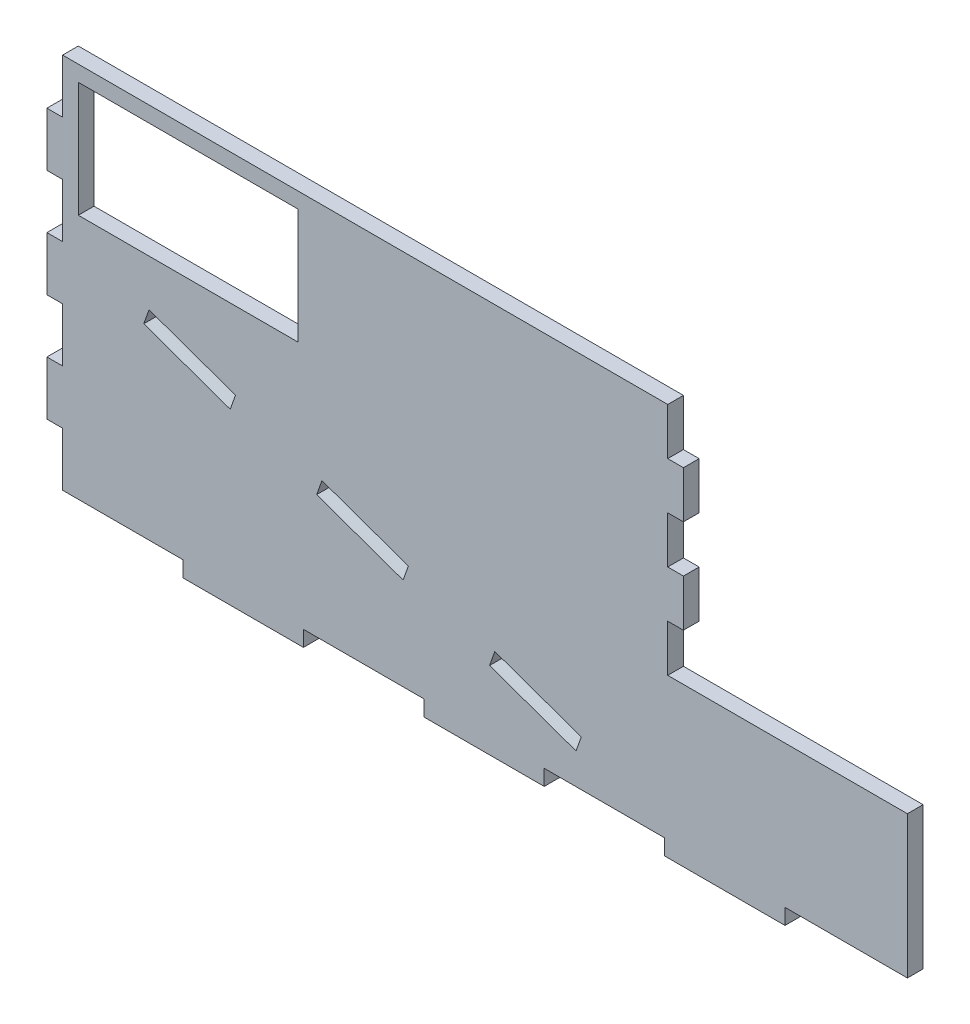
from build123d import *

# Parameters (mm, degrees)
SKETCH1_W           = 115.6
SKETCH1_H           = 72
BOSS_EXTRUDE1_DEPTH = 3
CUT_EXTRUDE1_REACH  = 5
SKETCH2_W           = 42
SKETCH2_H           = 22
SKETCH3_W           = 3
SKETCH3_H           = 10.29
SKETCH3_H_2         = 8.964
BOSS_EXTRUDE2_DEPTH = 3
SKETCH6_W           = 45.782864491
SKETCH6_H           = 27.18
BOSS_EXTRUDE4_DEPTH = 3
SKETCH8_W           = 23
SKETCH8_H           = 3
BOSS_EXTRUDE5_DEPTH = 3


with BuildPart() as part:
    # Sketch1 → Boss-Extrude1 (new body)
    with BuildSketch(Plane.XY):
        with Locations((57.8, 36)):
            Rectangle(SKETCH1_W, SKETCH1_H)
        Polygon((16.514285714, 38.123846184), (15.508587017, 35.297440316), (32.022872733, 29.421286499), (33.02857143, 32.247692367), align=None, mode=Mode.SUBTRACT)
        Polygon((49.542857146, 26.37153855), (48.537158448, 23.545132682), (65.051444164, 17.668978865), (66.057142861, 20.495384733), align=None, mode=Mode.SUBTRACT)
        Polygon((82.571428577, 14.619230916), (81.56572988, 11.792825048), (98.080015595, 5.916671232), (99.085714292, 8.743077099), align=None, mode=Mode.SUBTRACT)
    extrude(amount=BOSS_EXTRUDE1_DEPTH)

    # Sketch2 → Cut-Extrude1 (cut, up to next)
    with BuildSketch(Plane.XY.offset(3), mode=Mode.PRIVATE) as cut_extrude1_sk1:
        with Locations((24, 58)):
            Rectangle(SKETCH2_W, SKETCH2_H)
    cut_extrude1_tool1 = extrude(cut_extrude1_sk1.sketch, amount=-CUT_EXTRUDE1_REACH, mode=Mode.PRIVATE) & part.part
    add(cut_extrude1_tool1.solids().sort_by_distance((24, 58, 3))[0], mode=Mode.SUBTRACT)

    # Sketch3 → Boss-Extrude2 (add)
    with BuildSketch(Plane(origin=(0, 0, 0), x_dir=(-1, 0, 0), z_dir=(0, 0, -1))):
        with Locations((1.5, 56.569285714)):
            Rectangle(SKETCH3_W, SKETCH3_H)
        with Locations((1.5, 35.989285714)):
            Rectangle(SKETCH3_W, SKETCH3_H)
        with Locations((1.5, 15.409285714)):
            Rectangle(SKETCH3_W, SKETCH3_H)
        with Locations((-117.1, 58.554)):
            Rectangle(SKETCH3_W, SKETCH3_H_2)
        with Locations((-117.1, 40.626)):
            Rectangle(SKETCH3_W, SKETCH3_H_2)
    extrude(amount=-BOSS_EXTRUDE2_DEPTH)

    # Sketch6 → Boss-Extrude4 (add)
    with BuildSketch(Plane(origin=(0, 0, 0), x_dir=(-1, 0, 0), z_dir=(0, 0, -1))):
        with Locations((-138.491432246, 13.59)):
            Rectangle(SKETCH6_W, SKETCH6_H)
    extrude(amount=-BOSS_EXTRUDE4_DEPTH)

    # Sketch8 → Boss-Extrude5 (add)
    with BuildSketch(Plane(origin=(0, 0, 0), x_dir=(-1, 0, 0), z_dir=(0, 0, -1))):
        with Locations((-34.5, -1.5)):
            Rectangle(SKETCH8_W, SKETCH8_H)
        with Locations((-80.5, -1.5)):
            Rectangle(SKETCH8_W, SKETCH8_H)
        with Locations((-126.5, -1.5)):
            Rectangle(SKETCH8_W, SKETCH8_H)
    extrude(amount=-BOSS_EXTRUDE5_DEPTH)


solid = part.part
